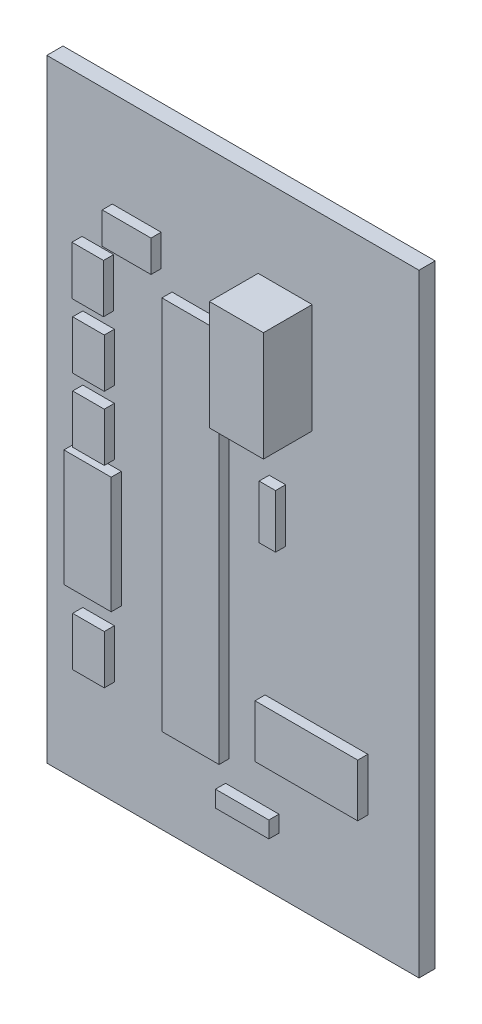
from build123d import *

# Parameters (mm, degrees)
SKETCH1_W                              = 36.81
SKETCH1_H                              = 60.63
BOARD_DEPTH                            = 1.6
SKETCH2_W                              = 7.9
SKETCH2_H                              = 3.8
TACT_PANA_EVQ_1_DEPTH                  = 1
SKETCH3_W                              = 4.826
SKETCH3_H                              = 3.1242
C025_030X050_1_DEPTH                   = 1
SKETCH4_W                              = 3.1242
SKETCH4_H                              = 4.826
C025_030X050_2_DEPTH                   = 1
SKETCH5_W                              = 3.1242
SKETCH5_H                              = 4.826
C025_030X050_3_DEPTH                   = 1
SKETCH6_W                              = 3.1242
SKETCH6_H                              = 4.826
C025_030X050_4_DEPTH                   = 1
SKETCH7_W                              = 3.1242
SKETCH7_H                              = 4.826
C025_030X050_5_DEPTH                   = 1
SKETCH8_W                              = 10.16
SKETCH8_H                              = 5.207
AB9V_1_DEPTH                           = 1
SKETCH9_W                              = 5.6515
SKETCH9_H                              = 37.1475
DIL28_1_DEPTH                          = 1
SKETCH10_W                             = 5.7024
SKETCH10_H                             = 5.4564
RGBLED5050_1_DEPTH                     = 1
SKETCH11_W                             = 5.345
SKETCH11_H                             = 10.83
TO254P482X997X1968_3P_4_820000_1_DEPTH = 4.82
SKETCH12_W                             = 1.6256
SKETCH12_H                             = 5.2832
AXIAL_0_3_1_DEPTH                      = 1
SKETCH13_W                             = 5.2832
SKETCH13_H                             = 1.6256
AXIAL_0_3_2_DEPTH                      = 1
SKETCH14_W                             = 4.1275
SKETCH14_H                             = 11.7475
EG1218_1_DEPTH                         = 1
SKETCH15_W                             = 4.6736
SKETCH15_H                             = 11.5316
HC49US_1_DEPTH                         = 1


with BuildPart() as part:
    # Sketch1 → BOARD (new body)
    with BuildSketch(Plane.XY):
        with Locations((18.405, 30.315)):
            Rectangle(SKETCH1_W, SKETCH1_H)
    extrude(amount=BOARD_DEPTH)


with BuildPart() as body_2:
    # Sketch2 → TACT_PANA-EVQ-1 (new body)
    with BuildSketch(Plane.XY):
        with Locations((29.21, 20.32)):
            Rectangle(SKETCH2_W, SKETCH2_H)
    extrude(amount=-TACT_PANA_EVQ_1_DEPTH)


with BuildPart() as body_3:
    # Sketch3 → C025-030X050-1 (new body)
    with BuildSketch(Plane.XY.offset(1.6)):
        with Locations((8.89, 49.5681)):
            Rectangle(SKETCH3_W, SKETCH3_H)
    extrude(amount=C025_030X050_1_DEPTH)


with BuildPart() as body_4:
    # Sketch4 → C025-030X050-2 (new body)
    with BuildSketch(Plane.XY.offset(1.6)):
        with Locations((5.0419, 44.45)):
            Rectangle(SKETCH4_W, SKETCH4_H)
    extrude(amount=C025_030X050_2_DEPTH)


with BuildPart() as body_5:
    # Sketch5 → C025-030X050-3 (new body)
    with BuildSketch(Plane.XY.offset(1.6)):
        with Locations((5.1181, 38.1)):
            Rectangle(SKETCH5_W, SKETCH5_H)
    extrude(amount=C025_030X050_3_DEPTH)


with BuildPart() as body_6:
    # Sketch6 → C025-030X050-4 (new body)
    with BuildSketch(Plane.XY.offset(1.6)):
        with Locations((5.1181, 31.75)):
            Rectangle(SKETCH6_W, SKETCH6_H)
    extrude(amount=C025_030X050_4_DEPTH)


with BuildPart() as body_7:
    # Sketch7 → C025-030X050-5 (new body)
    with BuildSketch(Plane.XY.offset(1.6)):
        with Locations((5.1181, 12.7)):
            Rectangle(SKETCH7_W, SKETCH7_H)
    extrude(amount=C025_030X050_5_DEPTH)


with BuildPart() as body_8:
    # Sketch8 → AB9V-1 (new body)
    with BuildSketch(Plane.XY.offset(1.6)):
        with Locations((26.67, 14.0335)):
            Rectangle(SKETCH8_W, SKETCH8_H)
    extrude(amount=AB9V_1_DEPTH)


with BuildPart() as body_9:
    # Sketch9 → DIL28-1 (new body)
    with BuildSketch(Plane.XY.offset(1.6)):
        with Locations((15.20825, 27.97175)):
            Rectangle(SKETCH9_W, SKETCH9_H)
    extrude(amount=DIL28_1_DEPTH)


with BuildPart() as body_10:
    # Sketch10 → RGBLED5050-1 (new body)
    with BuildSketch(Plane.XY):
        with Locations((28.9223, 32.8553)):
            Rectangle(SKETCH10_W, SKETCH10_H)
    extrude(amount=-RGBLED5050_1_DEPTH)


with BuildPart() as body_11:
    # Sketch11 → TO254P482X997X1968-3P_4.820000-1 (new body)
    with BuildSketch(Plane.XY.offset(1.6)):
        with Locations((23.5725, 46.99)):
            Rectangle(SKETCH11_W, SKETCH11_H)
    extrude(amount=TO254P482X997X1968_3P_4_820000_1_DEPTH)


with BuildPart() as body_12:
    # Sketch12 → AXIAL-0_3-1 (new body)
    with BuildSketch(Plane.XY.offset(1.6)):
        with Locations((22.8092, 33.02)):
            Rectangle(SKETCH12_W, SKETCH12_H)
    extrude(amount=AXIAL_0_3_1_DEPTH)


with BuildPart() as body_13:
    # Sketch13 → AXIAL-0_3-2 (new body)
    with BuildSketch(Plane.XY.offset(1.6)):
        with Locations((20.32, 6.2992)):
            Rectangle(SKETCH13_W, SKETCH13_H)
    extrude(amount=AXIAL_0_3_2_DEPTH)


with BuildPart() as body_14:
    # Sketch14 → EG1218-1 (new body)
    with BuildSketch(Plane.XY):
        with Locations((29.24175, 48.22825)):
            Rectangle(SKETCH14_W, SKETCH14_H)
    extrude(amount=-EG1218_1_DEPTH)


with BuildPart() as body_15:
    # Sketch15 → HC49US-1 (new body)
    with BuildSketch(Plane.XY.offset(1.6)):
        with Locations((5.0292, 22.9108)):
            Rectangle(SKETCH15_W, SKETCH15_H)
    extrude(amount=HC49US_1_DEPTH)


solid = Compound([part.part, body_2.part, body_3.part, body_4.part, body_5.part, body_6.part, body_7.part, body_8.part, body_9.part, body_10.part, body_11.part, body_12.part, body_13.part, body_14.part, body_15.part])
